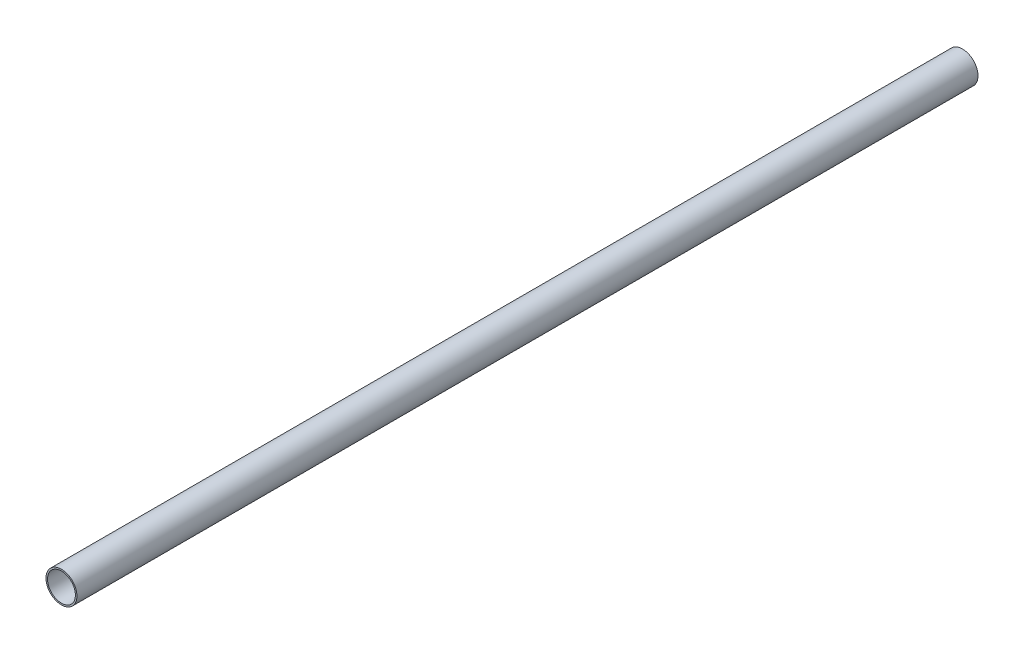
from build123d import *

# Parameters (mm, degrees)
SKETCH1_R           = 5
SKETCH1_R_2         = 4.5
EXTRUDE_THIN1_DEPTH = 291


with BuildPart() as part:
    # Sketch1 → Extrude-Thin1 (new body)
    with BuildSketch(Plane.XY):
        Circle(SKETCH1_R)
        Circle(SKETCH1_R_2, mode=Mode.SUBTRACT)
    extrude(amount=-EXTRUDE_THIN1_DEPTH)


solid = part.part
